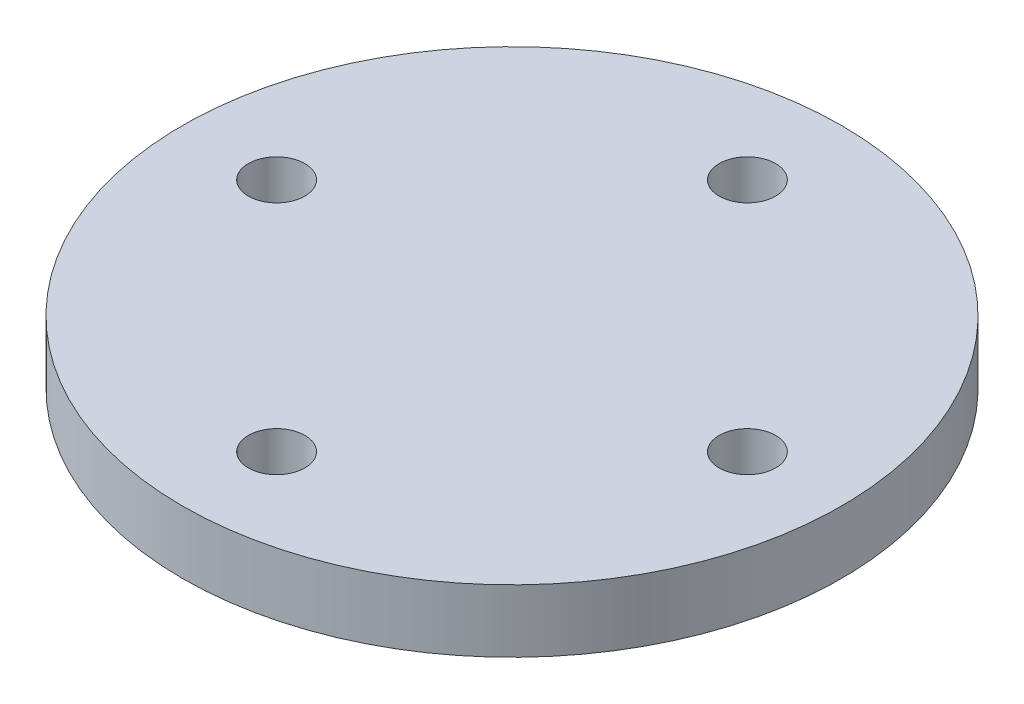
from build123d import *

# Parameters (mm, degrees)
SKETCH_1_R      = 10.5
SKETCH_1_R_2    = 0.9
EXTRUDE_1_DEPTH = 2


with BuildPart() as part:
    # Эскиз1 → Бобышка-Вытянуть1 (new body)
    with BuildSketch(Plane(origin=(0, 0, 0), x_dir=(1, 0, 0), z_dir=(0, 1, 0))):
        Circle(SKETCH_1_R)
        with Locations((0, -7.5)):
            Circle(SKETCH_1_R_2, mode=Mode.SUBTRACT)
        with Locations((0, 7.5)):
            Circle(SKETCH_1_R_2, mode=Mode.SUBTRACT)
        with Locations((-7.5, 3.4667e-05)):
            Circle(SKETCH_1_R_2, mode=Mode.SUBTRACT)
        with Locations((7.5, 0)):
            Circle(SKETCH_1_R_2, mode=Mode.SUBTRACT)
    extrude(amount=EXTRUDE_1_DEPTH)


solid = part.part
